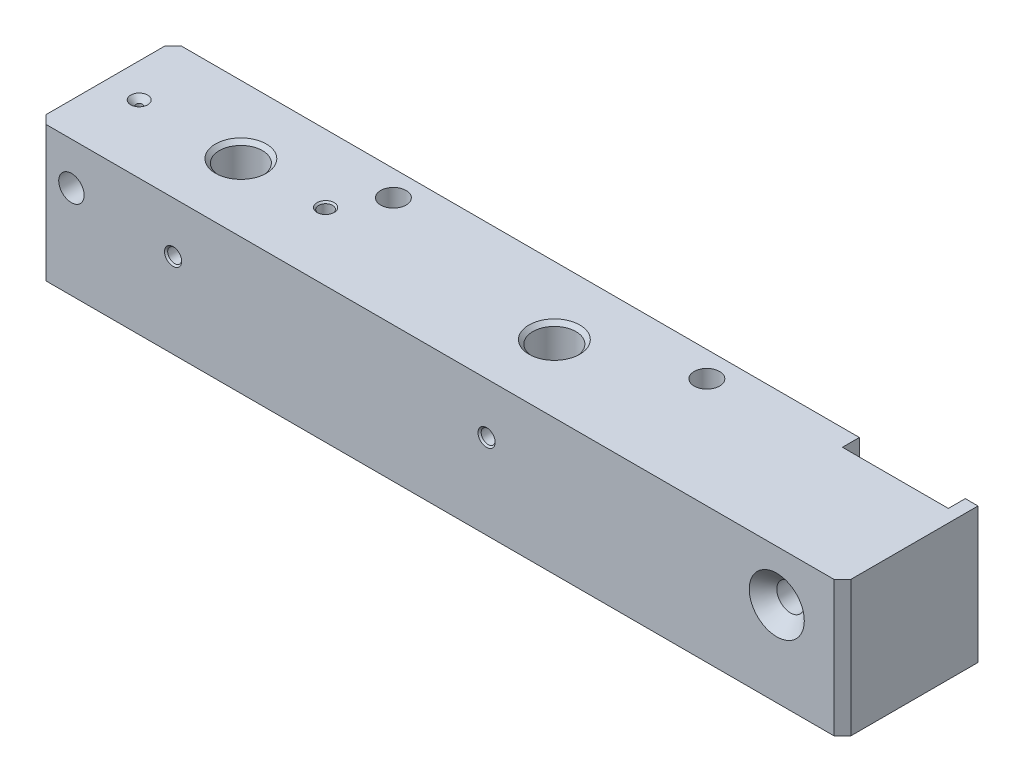
from build123d import *

# Parameters (mm, degrees)
SKETCH1_W                                            = 190
SKETCH1_H                                            = 32
BOSS_EXTRUDE1_DEPTH                                  = 16
CHAMFER1_SIZE                                        = 2
SKETCH2_W                                            = 25
SKETCH2_H                                            = 4
CUT_EXTRUDE1_DEPTH                                   = 33
M12_TAPPED_HOLE1_D                                   = 10.2
M12_TAPPED_HOLE1_DEPTH                               = 24
M12_TAPPED_HOLE1_CSINK_D                             = 12.005
M12_TAPPED_HOLE1_CSINK_ANGLE                         = 90
M12_TAPPED_HOLE1_TIP                                 = 3.064389157
M4_TAPPED_HOLE2_D                                    = 3.3
M4_TAPPED_HOLE2_DEPTH                                = 11.5
M4_TAPPED_HOLE2_CSINK_D                              = 4.05
M4_TAPPED_HOLE2_CSINK_ANGLE                          = 90
M4_TAPPED_HOLE2_TIP                                  = 0.991420021
CSK_FOR_M10_COUNTERSUNK_FLAT_HEAD_SCREW1_D           = 6.5
CSK_FOR_M10_COUNTERSUNK_FLAT_HEAD_SCREW1_CSINK_D     = 13
CSK_FOR_M10_COUNTERSUNK_FLAT_HEAD_SCREW1_CSINK_ANGLE = 90
SKETCH16_R                                           = 3
CUT_EXTRUDE2_DEPTH                                   = 33
CSK_FOR_M4_COUNTERSUNK_FLAT_HEAD_SCREW1_D            = 1.5
CSK_FOR_M4_COUNTERSUNK_FLAT_HEAD_SCREW1_DEPTH        = 10
CSK_FOR_M4_COUNTERSUNK_FLAT_HEAD_SCREW1_CSINK_D      = 4
CSK_FOR_M4_COUNTERSUNK_FLAT_HEAD_SCREW1_CSINK_ANGLE  = 90
CSK_FOR_M4_COUNTERSUNK_FLAT_HEAD_SCREW1_TIP          = 0.450645464
M4_TAPPED_HOLE3_D                                    = 3.3
M4_TAPPED_HOLE3_DEPTH                                = 16
M4_TAPPED_HOLE3_CSINK_D                              = 4.05
M4_TAPPED_HOLE3_CSINK_ANGLE                          = 90
M4_TAPPED_HOLE3_TIP                                  = 0.991420021
SKETCH24_R                                           = 3
CUT_EXTRUDE4_DEPTH                                   = 33


with BuildPart() as part:
    # Sketch1 → Boss-Extrude1 (new body, symmetric)
    with BuildSketch(Plane.XY):
        Rectangle(SKETCH1_W, SKETCH1_H)
    extrude(amount=BOSS_EXTRUDE1_DEPTH, both=True)

    # Chamfer1
    chamfer1_edges = [part.edges().sort_by_distance(p)[0] for p in [
        (-95, 0, 16),
        (95, 0, 16),
        (-95, 0, -16),
    ]]
    chamfer(chamfer1_edges, length=CHAMFER1_SIZE)

    # Sketch2 → Cut-Extrude1 (cut, through all)
    with BuildSketch(Plane(origin=(0, 16, 0), x_dir=(1, 0, 0), z_dir=(0, 1, 0))):
        with Locations((79.5, 14)):
            Rectangle(SKETCH2_W, SKETCH2_H)
    extrude(amount=-CUT_EXTRUDE1_DEPTH, mode=Mode.SUBTRACT)

    # M12 Tapped Hole1
    with Locations(Plane(origin=(0, 16, 0), x_dir=(1, 0, 0), z_dir=(0, 1, 0))):
        with Locations((-63, 0), (11, 0)):
            CounterSinkHole(M12_TAPPED_HOLE1_D / 2, M12_TAPPED_HOLE1_CSINK_D / 2, depth=M12_TAPPED_HOLE1_DEPTH, counter_sink_angle=M12_TAPPED_HOLE1_CSINK_ANGLE)
            with Locations((0, 0, -(M12_TAPPED_HOLE1_DEPTH + M12_TAPPED_HOLE1_TIP / 2))):  # 118° drill point
                Cone(0, M12_TAPPED_HOLE1_D / 2, M12_TAPPED_HOLE1_TIP, mode=Mode.SUBTRACT)

    # M4 Tapped Hole2
    with Locations(Plane(origin=(-63, 4, 16), x_dir=(1, 0, 0), z_dir=(0, 0, 1))):
        with Locations((0, 0), (74, 0)):
            CounterSinkHole(M4_TAPPED_HOLE2_D / 2, M4_TAPPED_HOLE2_CSINK_D / 2, depth=M4_TAPPED_HOLE2_DEPTH, counter_sink_angle=M4_TAPPED_HOLE2_CSINK_ANGLE)
            with Locations((0, 0, -(M4_TAPPED_HOLE2_DEPTH + M4_TAPPED_HOLE2_TIP / 2))):  # 118° drill point
                Cone(0, M4_TAPPED_HOLE2_D / 2, M4_TAPPED_HOLE2_TIP, mode=Mode.SUBTRACT)

    # CSK for M10 Countersunk Flat Head Screw1 (through all)
    with Locations(Plane.XY.offset(16)):
        with Locations((79.5, 4)):
            CounterSinkHole(CSK_FOR_M10_COUNTERSUNK_FLAT_HEAD_SCREW1_D / 2, CSK_FOR_M10_COUNTERSUNK_FLAT_HEAD_SCREW1_CSINK_D / 2, counter_sink_angle=CSK_FOR_M10_COUNTERSUNK_FLAT_HEAD_SCREW1_CSINK_ANGLE)

    # Sketch16 → Cut-Extrude2 (cut, through all)
    with BuildSketch(Plane.XY.offset(16)):
        with Locations((-87, 6)):
            Circle(SKETCH16_R)
    extrude(amount=-CUT_EXTRUDE2_DEPTH, mode=Mode.SUBTRACT)

    # CSK for M4 Countersunk Flat Head Screw1
    with Locations(Plane(origin=(0, 16, 0), x_dir=(1, 0, 0), z_dir=(0, 1, 0))):
        with Locations((-87, 0)):
            CounterSinkHole(CSK_FOR_M4_COUNTERSUNK_FLAT_HEAD_SCREW1_D / 2, CSK_FOR_M4_COUNTERSUNK_FLAT_HEAD_SCREW1_CSINK_D / 2, depth=CSK_FOR_M4_COUNTERSUNK_FLAT_HEAD_SCREW1_DEPTH, counter_sink_angle=CSK_FOR_M4_COUNTERSUNK_FLAT_HEAD_SCREW1_CSINK_ANGLE)
            with Locations((0, 0, -(CSK_FOR_M4_COUNTERSUNK_FLAT_HEAD_SCREW1_DEPTH + CSK_FOR_M4_COUNTERSUNK_FLAT_HEAD_SCREW1_TIP / 2))):  # 118° drill point
                Cone(0, CSK_FOR_M4_COUNTERSUNK_FLAT_HEAD_SCREW1_D / 2, CSK_FOR_M4_COUNTERSUNK_FLAT_HEAD_SCREW1_TIP, mode=Mode.SUBTRACT)

    # M4 Tapped Hole3
    with Locations(Plane(origin=(0, 16, 0), x_dir=(1, 0, 0), z_dir=(0, 1, 0))):
        with Locations((-43, 0)):
            CounterSinkHole(M4_TAPPED_HOLE3_D / 2, M4_TAPPED_HOLE3_CSINK_D / 2, depth=M4_TAPPED_HOLE3_DEPTH, counter_sink_angle=M4_TAPPED_HOLE3_CSINK_ANGLE)
            with Locations((0, 0, -(M4_TAPPED_HOLE3_DEPTH + M4_TAPPED_HOLE3_TIP / 2))):  # 118° drill point
                Cone(0, M4_TAPPED_HOLE3_D / 2, M4_TAPPED_HOLE3_TIP, mode=Mode.SUBTRACT)

    # Sketch24 → Cut-Extrude4 (cut, through all)
    with BuildSketch(Plane(origin=(0, 16, 0), x_dir=(1, 0, 0), z_dir=(0, 1, 0))):
        with Locations((-37, 10)):
            Circle(SKETCH24_R)
        with Locations((37, 10)):
            Circle(SKETCH24_R)
    extrude(amount=-CUT_EXTRUDE4_DEPTH, mode=Mode.SUBTRACT)


solid = part.part
